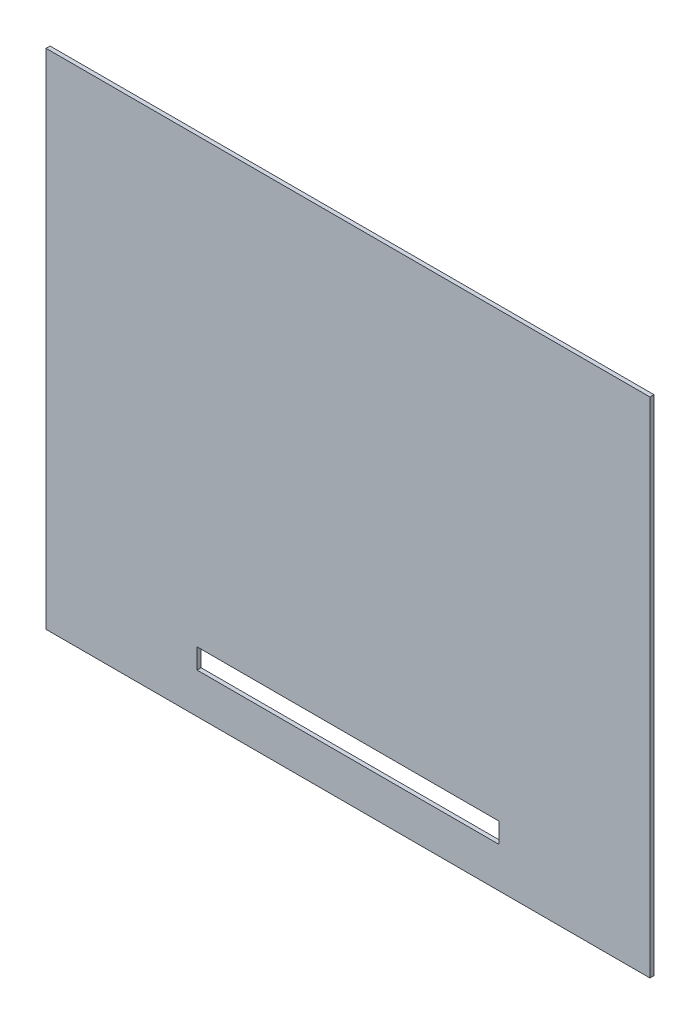
from build123d import *

# Parameters (mm, degrees)
SKETCH1_W           = 300
SKETCH1_H           = 250
BOSS_EXTRUDE1_DEPTH = 2
SKETCH5_W           = 150
SKETCH5_H           = 10
CUT_EXTRUDE1_DEPTH  = 3


with BuildPart() as part:
    # Sketch1 → Boss-Extrude1 (new body)
    with BuildSketch(Plane.XY):
        Rectangle(SKETCH1_W, SKETCH1_H)
    extrude(amount=BOSS_EXTRUDE1_DEPTH)

    # Sketch5 → Cut-Extrude1 (cut, through all)
    with BuildSketch(Plane(origin=(0, 0, 0), x_dir=(-1, 0, 0), z_dir=(0, 0, -1))):
        with Locations((0, -100)):
            Rectangle(SKETCH5_W, SKETCH5_H)
    extrude(amount=-CUT_EXTRUDE1_DEPTH, mode=Mode.SUBTRACT)


solid = part.part
